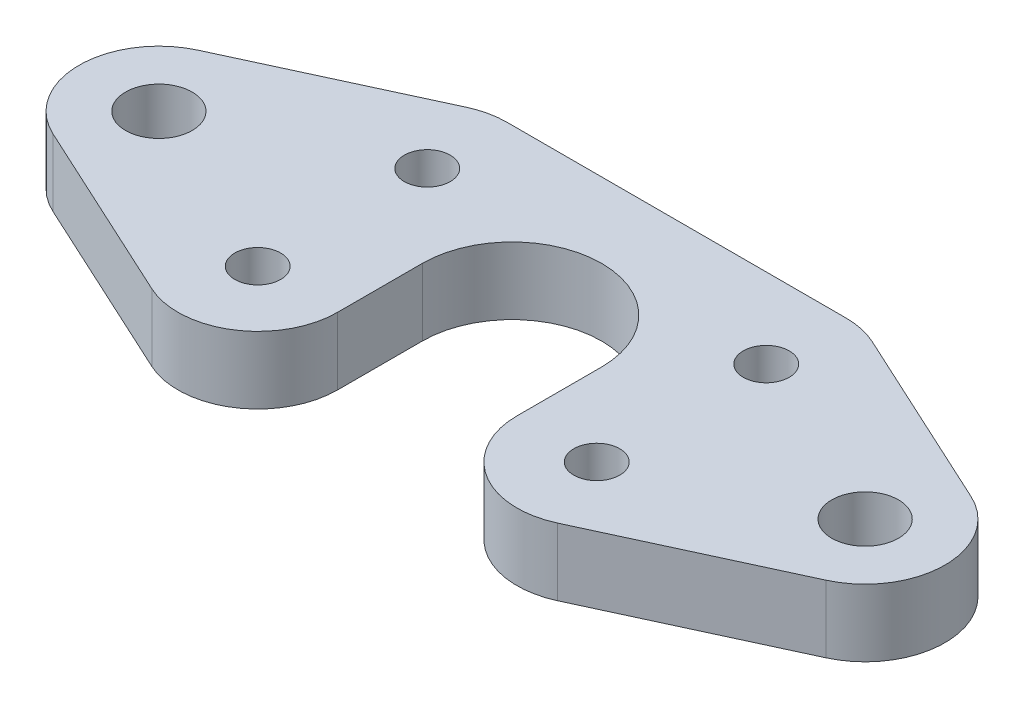
from build123d import *

# Parameters (mm, degrees)
SKETCH1_R           = 2.36
SKETCH1_R_2         = 1.625
BOSS_EXTRUDE1_DEPTH = 4.7625


with BuildPart() as part:
    # Sketch1 → Boss-Extrude1 (new body)
    with BuildSketch(Plane(origin=(0, 0, 0), x_dir=(1, 0, 0), z_dir=(0, 1, 0))):
        with BuildLine():
            Line((0, 6.35), (0, 11.65))
            Line((0, 11.65), (-12, 11.65))
            ThreePointArc((-12, 11.65), (-13.212057455, 11.518461446), (-14.367678703, 11.129970522))
            Line((-14.367678703, 11.129970522), (-27.367678703, 5.129970522))
            ThreePointArc((-27.367678703, 5.129970522), (-30.65, 0), (-27.367678703, -5.129970522))
            Line((-27.367678703, -5.129970522), (-14.367678703, -11.129970522))
            ThreePointArc((-14.367678703, -11.129970522), (-8.954912536, -10.759195555), (-6.35, -6))
            Line((-6.35, -6), (-6.35, 0))
            ThreePointArc((-6.35, 0), (-4.490128061, 4.490128061), (0, 6.35))
        make_face()
        with Locations((-25, 0)):
            Circle(SKETCH1_R, mode=Mode.SUBTRACT)
        with Locations((-12, 6)):
            Circle(SKETCH1_R_2, mode=Mode.SUBTRACT)
        with Locations((-12, -6)):
            Circle(SKETCH1_R_2, mode=Mode.SUBTRACT)
    boss_extrude1 = extrude(amount=BOSS_EXTRUDE1_DEPTH)

    # Mirror1: Boss-Extrude1 across plane
    add(boss_extrude1.mirror(Plane(origin=(0, 4.7625, -6.35), x_dir=(0, 0, 1), z_dir=(-1, 0, 0))))


solid = part.part
